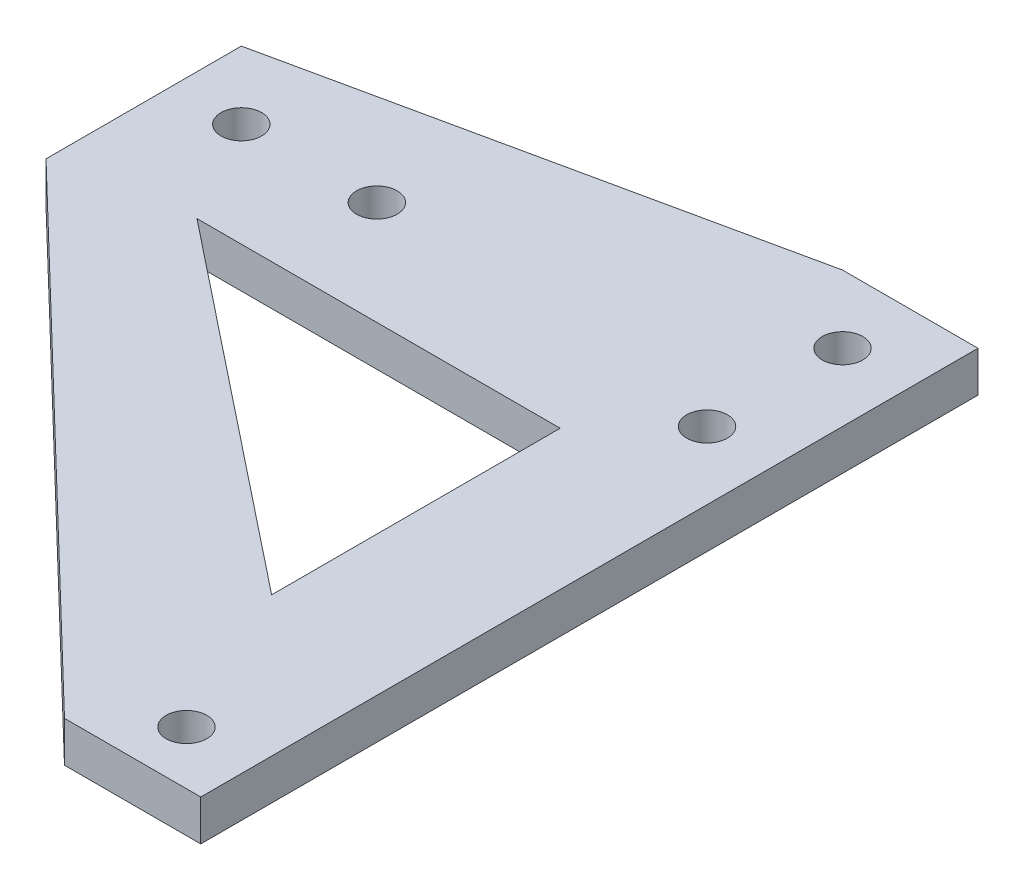
from build123d import *

# Parameters (mm, degrees)
SKETCH1_R           = 1.5
BOSS_EXTRUDE1_DEPTH = 3
SKETCH4_R           = 1.5
CUT_EXTRUDE2_DEPTH  = 7
SKETCH5_W           = 46.5
SKETCH5_H           = 2
CUT_EXTRUDE3_DEPTH  = 7
CUT_EXTRUDE4_DEPTH  = 7
CUT_EXTRUDE5_DEPTH  = 7


with BuildPart() as part:
    # Sketch1 → Boss-Extrude1 (new body)
    with BuildSketch(Plane(origin=(0, 0, 0), x_dir=(1, 0, 0), z_dir=(0, 1, 0))):
        Polygon((5, 16.666723622), (5, 56.73), (-5, 56.73), (-5, 5.234024539), (5, 5.234024539), (31.5, 5.234024539), (41.5, 5.234024539), (41.5, 64.6), (31.5, 64.6), (31.5, 54.48), (31.5, 16.666723622), align=None)
        with Locations((0, 10.18)):
            Circle(SKETCH1_R, mode=Mode.SUBTRACT)
        with Locations((36.5, 11.18)):
            Circle(SKETCH1_R, mode=Mode.SUBTRACT)
        with Locations((0, 51.73)):
            Circle(SKETCH1_R, mode=Mode.SUBTRACT)
        with Locations((36.5, 49.6)):
            Circle(SKETCH1_R, mode=Mode.SUBTRACT)
        with Locations((36.5, 59.6)):
            Circle(SKETCH1_R, mode=Mode.SUBTRACT)
        Polygon((-5, 56.73), (5, 56.73), (31.5, 54.48), (31.5, 64.6), align=None)
        Polygon((31.5, 54.48), (5, 56.73), (5, 16.666723622), (31.5, 16.666723622), align=None)
    extrude(amount=BOSS_EXTRUDE1_DEPTH)

    # Sketch4 → Cut-Extrude2 (cut)
    with BuildSketch(Plane(origin=(0, 3, 0), x_dir=(1, 0, 0), z_dir=(0, 1, 0))):
        with Locations((10, 51.73)):
            Circle(SKETCH4_R)
    extrude(amount=-CUT_EXTRUDE2_DEPTH, mode=Mode.SUBTRACT)

    # Sketch5 → Cut-Extrude3 (cut)
    with BuildSketch(Plane(origin=(0, 3, 0), x_dir=(1, 0, 0), z_dir=(0, 1, 0))):
        with Locations((18.25, 6.234024539)):
            Rectangle(SKETCH5_W, SKETCH5_H)
    extrude(amount=-CUT_EXTRUDE3_DEPTH, mode=Mode.SUBTRACT)

    # Sketch6 → Cut-Extrude4 (cut)
    with BuildSketch(Plane(origin=(0, 3, 0), x_dir=(1, 0, 0), z_dir=(0, 1, 0))):
        Polygon((31.443621834, 7.234024539), (-5, 42.312799573), (-5, 7.234024539), align=None)
    extrude(amount=-CUT_EXTRUDE4_DEPTH, mode=Mode.SUBTRACT)

    # Sketch7 → Cut-Extrude5 (cut)
    with BuildSketch(Plane(origin=(0, 3, 0), x_dir=(1, 0, 0), z_dir=(0, 1, 0))):
        Polygon((31.193110027, 22.772878628), (31.193110027, 44.066382221), (4.388346681, 44.066382221), align=None)
    extrude(amount=-CUT_EXTRUDE5_DEPTH, mode=Mode.SUBTRACT)


solid = part.part
